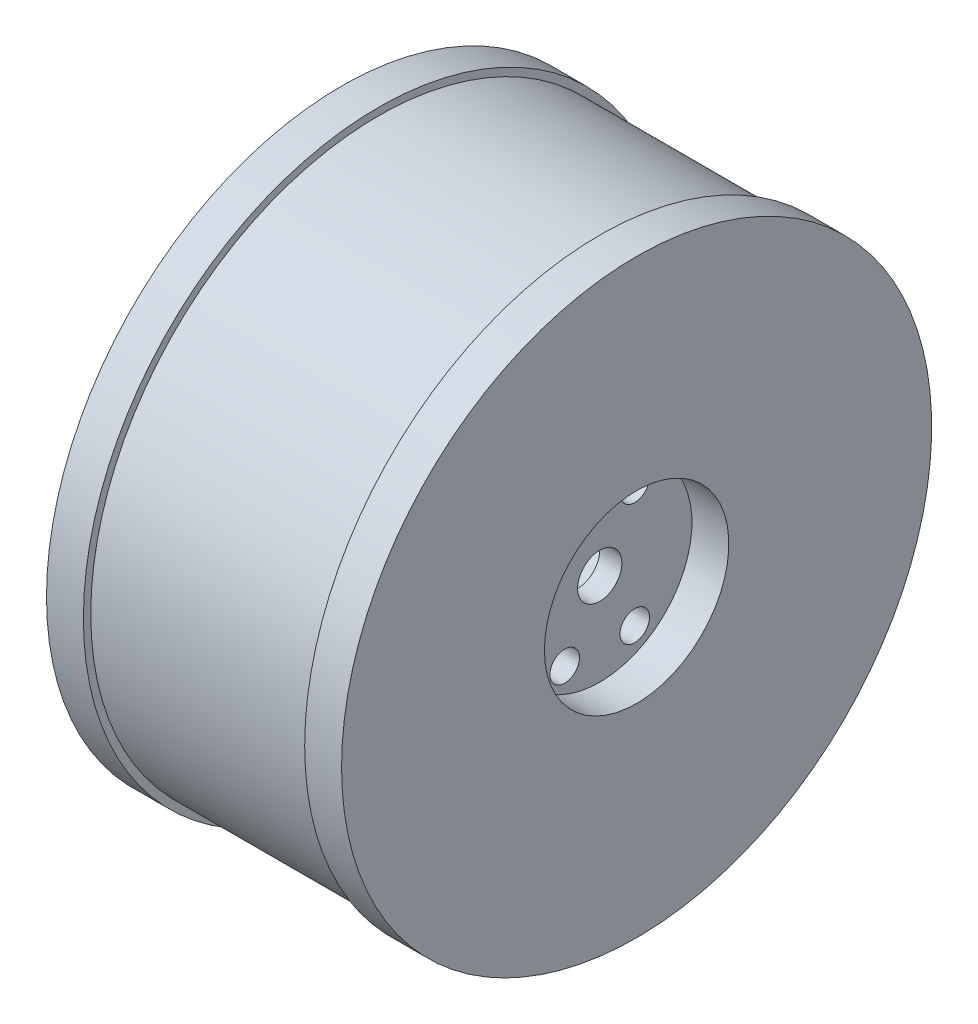
from build123d import *

# Parameters (mm, degrees)
ESQUISSE2_W             = 5
ESQUISSE2_H             = 12.5
ESQUISSE3_R             = 2
ENL_V_MAT_EXTRU_1_DEPTH = 36
ESQUISSE4_R             = 3
ENL_V_MAT_EXTRU_2_DEPTH = 36


with BuildPart() as part:
    # Esquisse1 → Révolution1 (revolve)
    with BuildSketch(Plane.XY):
        Polygon((0, 34), (0, 0), (8, 0), (8, 40), (3, 40), (3, 39), (-27, 39), (-27, 40), (-32, 40), (-32, 34), align=None)
    revolve(axis=Axis((-49.644499027, 0, 0), (1, 0, 0)))

    # Esquisse2 → Enlèvement de matière-Révolution1 (revolve, cut)
    with BuildSketch(Plane.XY):
        with Locations((5.5, 6.25)):
            Rectangle(ESQUISSE2_W, ESQUISSE2_H)
    revolve(axis=Axis((0, 0, 0), (1, 0, 0)), mode=Mode.SUBTRACT)

    # Esquisse3 → Enlèv. mat.-Extru.1 (cut, through all)
    with BuildSketch(Plane(origin=(3, 0, 0), x_dir=(0, 0, -1), z_dir=(1, 0, 0))):
        with Locations((4.75, 8.227241336)):
            Circle(ESQUISSE3_R)
        with Locations((-4.75, 8.227241336)):
            Circle(ESQUISSE3_R)
        with Locations((4.75, -8.227241336)):
            Circle(ESQUISSE3_R)
        with Locations((-4.75, -8.227241336)):
            Circle(ESQUISSE3_R)
    extrude(amount=-ENL_V_MAT_EXTRU_1_DEPTH, mode=Mode.SUBTRACT)

    # Esquisse4 → Enlèv. mat.-Extru.2 (cut, through all)
    with BuildSketch(Plane(origin=(3, 0, 0), x_dir=(0, 0, -1), z_dir=(1, 0, 0))):
        Circle(ESQUISSE4_R)
    extrude(amount=-ENL_V_MAT_EXTRU_2_DEPTH, mode=Mode.SUBTRACT)


solid = part.part
